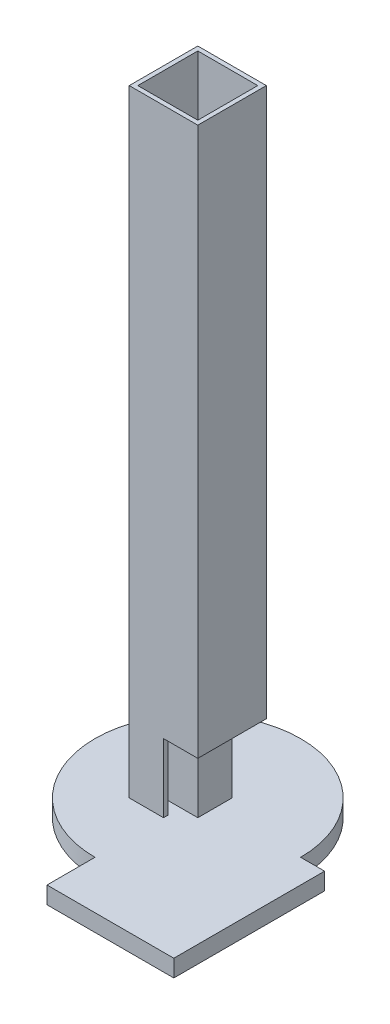
from build123d import *

# Parameters (mm, degrees)
SKETCH1_R           = 38.1
BOSS_EXTRUDE1_DEPTH = 6.35
SKETCH4_W           = 25.4
SKETCH4_H           = 25.4
BOSS_EXTRUDE2_DEPTH = 228.6
SKETCH5_W           = 22.225
SKETCH5_H           = 22.225
CUT_EXTRUDE1_DEPTH  = 228.6
SKETCH8_W           = 12.7
SKETCH8_H           = 25.4
CUT_EXTRUDE2_DEPTH  = 25.4
SKETCH7_W           = 12.7
SKETCH7_H           = 12.7
BOSS_EXTRUDE4_DEPTH = 203.2
SKETCH9_W           = 46.99
SKETCH9_H           = 55.88
BOSS_EXTRUDE5_DEPTH = 6.35


with BuildPart() as part:
    # Sketch1 → Boss-Extrude1 (new body)
    with BuildSketch(Plane(origin=(0, 0, 0), x_dir=(1, 0, 0), z_dir=(0, 1, 0))):
        Circle(SKETCH1_R)
    extrude(amount=BOSS_EXTRUDE1_DEPTH)

    # Sketch4 → Boss-Extrude2 (add)
    with BuildSketch(Plane(origin=(0, 6.35, 0), x_dir=(1, 0, 0), z_dir=(0, 1, 0))):
        Rectangle(SKETCH4_W, SKETCH4_H)
    extrude(amount=BOSS_EXTRUDE2_DEPTH)

    # Sketch5 → Cut-Extrude1 (cut)
    with BuildSketch(Plane(origin=(0, 234.95, 0), x_dir=(1, 0, 0), z_dir=(0, 1, 0))):
        Rectangle(SKETCH5_W, SKETCH5_H)
    extrude(amount=-CUT_EXTRUDE1_DEPTH, mode=Mode.SUBTRACT)

    # Sketch8 → Cut-Extrude2 (cut)
    with BuildSketch(Plane.XY.offset(12.7)):
        with Locations((6.35, 19.05)):
            Rectangle(SKETCH8_W, SKETCH8_H)
    extrude(amount=-CUT_EXTRUDE2_DEPTH, mode=Mode.SUBTRACT)

    # Sketch7 → Boss-Extrude4 (add)
    with BuildSketch(Plane(origin=(0, 6.35, 0), x_dir=(1, 0, 0), z_dir=(0, 1, 0))):
        Rectangle(SKETCH7_W, SKETCH7_H)
    extrude(amount=BOSS_EXTRUDE4_DEPTH)

    # Sketch9 → Boss-Extrude5 (add)
    with BuildSketch(Plane.XZ):
        with Locations((23.495, 27.94)):
            Rectangle(SKETCH9_W, SKETCH9_H)
    extrude(amount=-BOSS_EXTRUDE5_DEPTH)


solid = part.part
